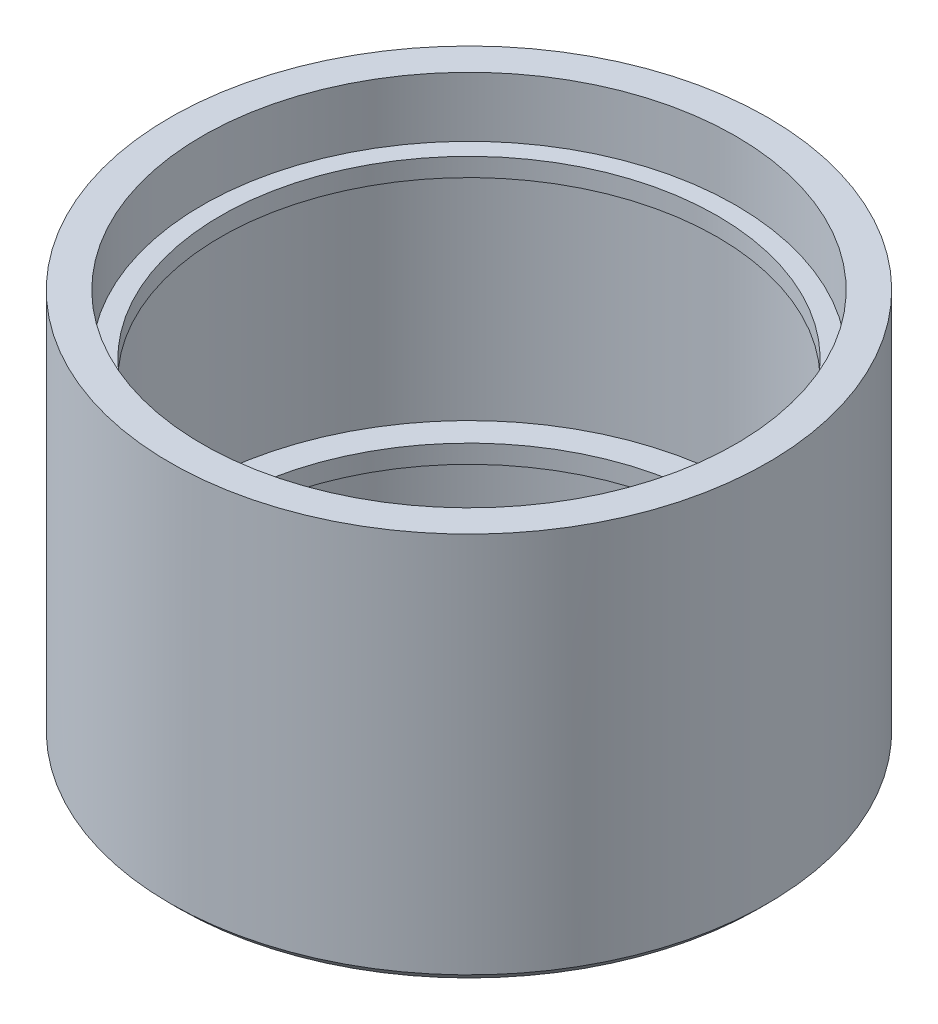
from build123d import *

# Parameters (mm, degrees)
CHAMFER1_SIZE = 1


with BuildPart() as part:
    # Sketch3 → Revolve2 (revolve)
    with BuildSketch(Plane(origin=(0, 0, 0), x_dir=(0, 0, -1), z_dir=(1, 0, 0))):
        Polygon((-29, -21.25), (-29, -14.25), (-27, -14.25), (-27, -12.25), (-30, -12.25), (-30, 12.75), (-27, 12.75), (-27, 14.75), (-29, 14.75), (-29, 21.25), (-32.5, 21.25), (-32.5, -21.25), align=None)
    revolve(axis=Axis((0, -21.25, 0), (0, 1, 0)))

    # Chamfer1
    chamfer1_edges = [part.edges().sort_by_distance(p)[0] for p in [
        (0, -21.25, -32.5),
    ]]
    chamfer(chamfer1_edges, length=CHAMFER1_SIZE)


solid = part.part
